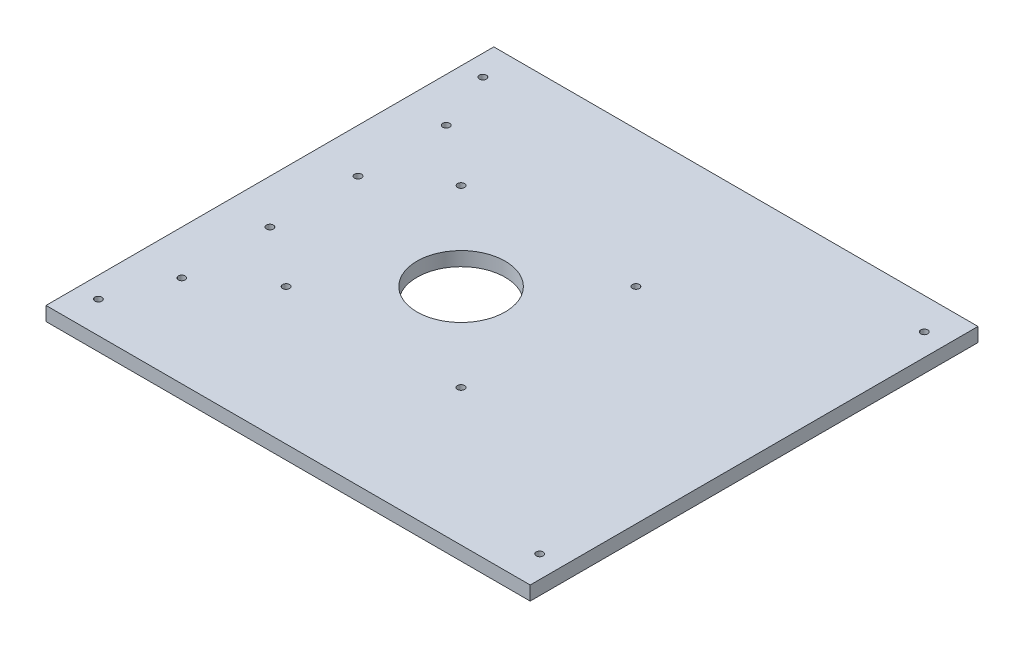
from build123d import *

# Parameters (mm, degrees)
SKETCH1_W           = 219.71
SKETCH1_H           = 203.2
BOSS_EXTRUDE1_DEPTH = 6.35
SKETCH2_R           = 1.5875
SKETCH2_R_2         = 20.000000005
CUT_EXTRUDE3_DEPTH  = 7.35


with BuildPart() as part:
    # Sketch1 → Boss-Extrude1 (new body)
    with BuildSketch(Plane(origin=(0, 0, 0), x_dir=(1, 0, 0), z_dir=(0, 1, 0))):
        with Locations((28.489079589, -66.894525566)):
            Rectangle(SKETCH1_W, SKETCH1_H)
    extrude(amount=BOSS_EXTRUDE1_DEPTH)

    # Sketch2 → Cut-Extrude3 (cut, through all)
    with BuildSketch(Plane(origin=(0, 6.35, 0), x_dir=(1, 0, 0), z_dir=(0, 1, 0))):
        with Locations((-61.365920533, -46.894525561)):
            Circle(SKETCH2_R)
        with Locations((128.298379589, -154.143525566)):
            Circle(SKETCH2_R)
        with Locations((128.298379589, 20.354474434)):
            Circle(SKETCH2_R)
        with Locations((-71.955220411, 20.354474434)):
            Circle(SKETCH2_R)
        with Locations((-71.955220411, -154.143525566)):
            Circle(SKETCH2_R)
        with Locations((-61.365920533, -6.894525551)):
            Circle(SKETCH2_R)
        with Locations((-61.365920533, -86.894525571)):
            Circle(SKETCH2_R)
        with Locations((-61.365920533, -126.894525327)):
            Circle(SKETCH2_R)
        with Locations((5.381145499, -66.894525566)):
            Circle(SKETCH2_R_2)
        with Locations((45.036895499, -106.582025566)):
            Circle(SKETCH2_R)
        with Locations((-34.306354501, -106.582025566)):
            Circle(SKETCH2_R)
        with Locations((-34.306354501, -27.207025566)):
            Circle(SKETCH2_R)
        with Locations((45.036895499, -27.207025566)):
            Circle(SKETCH2_R)
    extrude(amount=-CUT_EXTRUDE3_DEPTH, mode=Mode.SUBTRACT)


solid = part.part
